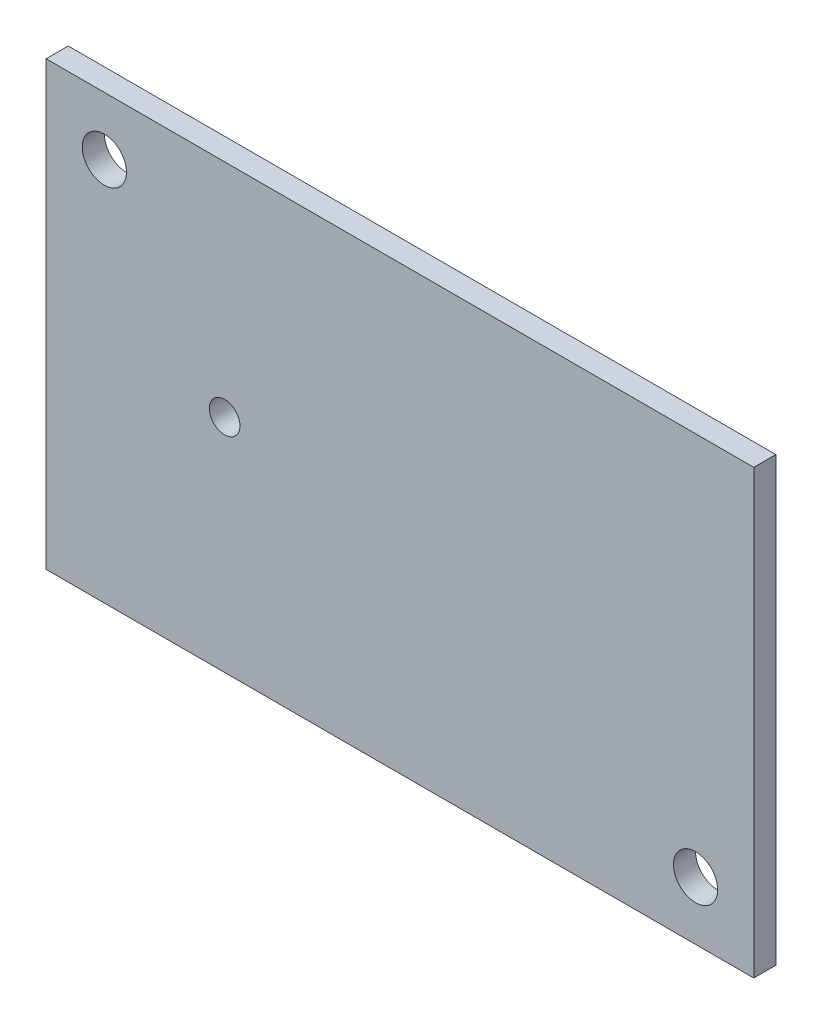
from build123d import *

# Parameters (mm, degrees)
SKETCH1_W           = 101.6
SKETCH1_H           = 63.5
BOSS_EXTRUDE1_DEPTH = 3.175
SKETCH2_R           = 3.175
CUT_EXTRUDE1_DEPTH  = 3.175
SKETCH3_R           = 2.199978507
CUT_EXTRUDE2_DEPTH  = 3.175


with BuildPart() as part:
    # Sketch1 → Boss-Extrude1 (new body)
    with BuildSketch(Plane.XY):
        with Locations((-35.329090909, 0.577272727)):
            Rectangle(SKETCH1_W, SKETCH1_H)
    extrude(amount=BOSS_EXTRUDE1_DEPTH)

    # Sketch2 → Cut-Extrude1 (cut)
    with BuildSketch(Plane.XY.offset(3.175)):
        with Locations((-77.769090909, 23.967272727)):
            Circle(SKETCH2_R)
        with Locations((7.115909091, -22.812727273)):
            Circle(SKETCH2_R)
    extrude(amount=-CUT_EXTRUDE1_DEPTH, mode=Mode.SUBTRACT)

    # Sketch3 → Cut-Extrude2 (cut)
    with BuildSketch(Plane.XY.offset(3.175)):
        with Locations((-60.499797011, 0.581401186)):
            Circle(SKETCH3_R)
    extrude(amount=-CUT_EXTRUDE2_DEPTH, mode=Mode.SUBTRACT)


solid = part.part
